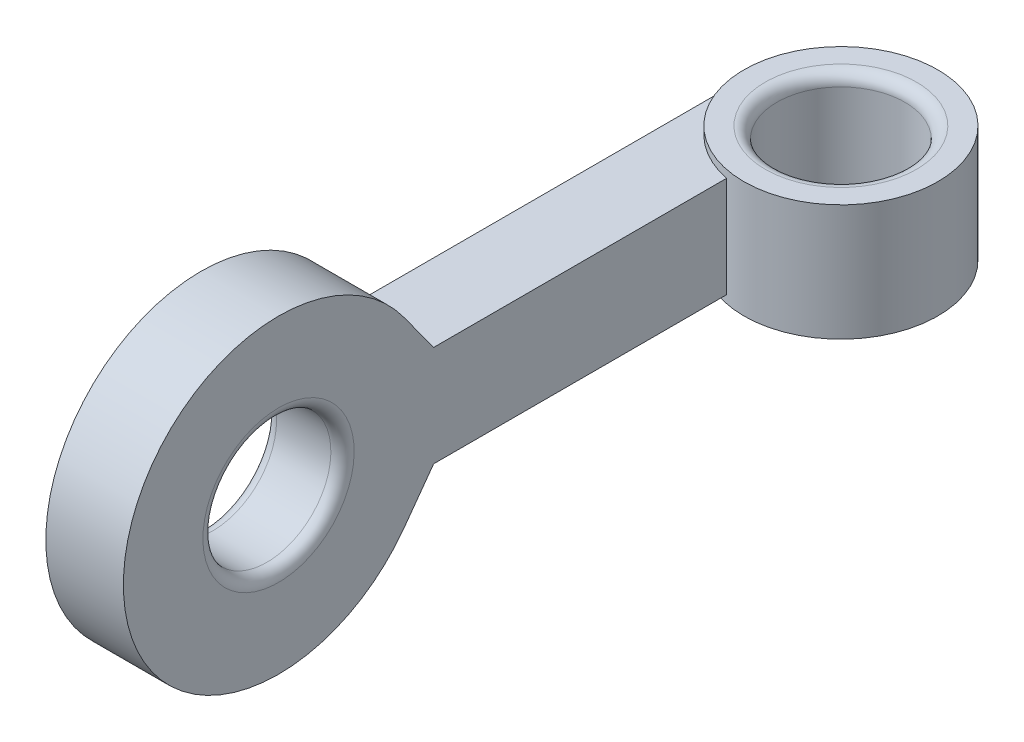
from build123d import *

# Parameters (mm, degrees)
SKETCH_1_R          = 2.5
SKETCH_1_R_2        = 1.65
EXTRUDE_1_DEPTH     = 3
EXTRUDE_2_REACH     = 14.5
SKETCH_2_W          = 2
SKETCH_2_H          = 2.6
EXTRUDE_3_DEPTH     = 2
CUT_EXTRUDE_1_REACH = 4
SKETCH_4_R          = 1.65
FILLET_1_R          = 0.3
FILLET_2_R          = 0.3
FILLET_3_R          = 0.3
FILLET_4_R          = 0.3


with BuildPart() as part:
    # 草图1 → 凸台-拉伸1 (new body)
    with BuildSketch(Plane(origin=(0, 0, 0), x_dir=(1, 0, 0), z_dir=(0, 1, 0))):
        Circle(SKETCH_1_R)
        Circle(SKETCH_1_R_2, mode=Mode.SUBTRACT)
    extrude(amount=EXTRUDE_1_DEPTH)

    # 草图2 → 凸台-拉伸2 (add, up to next)
    with BuildSketch(Plane.XY.offset(10), mode=Mode.PRIVATE) as extrude_2_sk1:
        with Locations((-1.5, 1.5)):
            Rectangle(SKETCH_2_W, SKETCH_2_H)
    extrude_2_tool1 = extrude(extrude_2_sk1.sketch, amount=-EXTRUDE_2_REACH, mode=Mode.PRIVATE) - part.part
    add(extrude_2_tool1.solids().sort_by_distance((-1.5, 1.5, 10))[0])

    # 草图3 → 凸台-拉伸3 (add)
    with BuildSketch(Plane.ZY.offset(2.5)):
        with BuildLine():
            Line((10, 2.8), (10, 0.2))
            Line((10, 0.2), (10.764273601, -0.85161108))
            ThreePointArc((10.764273601, -0.85161108), (18, 1.5), (10.764273601, 3.85161108))
            Line((10.764273601, 3.85161108), (10, 2.8))
        make_face()
    extrude(amount=-EXTRUDE_3_DEPTH)

    # 草图4 → 切除-拉伸1 (cut, up to next)
    with BuildSketch(Plane(origin=(-0.5, 0, 0), x_dir=(0, 0, -1), z_dir=(1, 0, 0)), mode=Mode.PRIVATE) as cut_extrude_1_sk1:
        with Locations((-14, 1.5)):
            Circle(SKETCH_4_R)
    cut_extrude_1_tool1 = extrude(cut_extrude_1_sk1.sketch, amount=-CUT_EXTRUDE_1_REACH, mode=Mode.PRIVATE) & part.part
    add(cut_extrude_1_tool1.solids().sort_by_distance((-0.5, 1.5, 14))[0], mode=Mode.SUBTRACT)

    # 圆角1
    fillet_1_edges = [part.edges().sort_by_distance(p)[0] for p in [
        (-0.5, 1.5, 15.65),
    ]]
    fillet(fillet_1_edges, radius=FILLET_1_R)

    # 圆角2
    fillet_2_edges = [part.edges().sort_by_distance(p)[0] for p in [
        (-1.65, 3, 0),
    ]]
    fillet(fillet_2_edges, radius=FILLET_2_R)

    # 圆角3
    fillet_3_edges = [part.edges().sort_by_distance(p)[0] for p in [
        (-1.65, 0, 0),
    ]]
    fillet(fillet_3_edges, radius=FILLET_3_R)

    # 圆角4
    fillet_4_edges = [part.edges().sort_by_distance(p)[0] for p in [
        (-2.5, 1.5, 15.65),
    ]]
    fillet(fillet_4_edges, radius=FILLET_4_R)


solid = part.part
